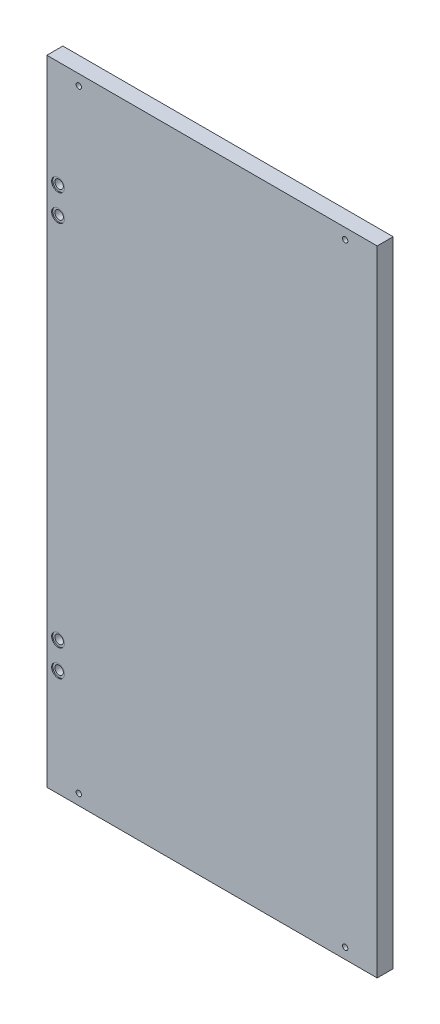
from build123d import *

# Parameters (mm, degrees)
SKETCH_1_W               = 310
SKETCH_1_H               = 595
EXTRUDE_1_DEPTH          = 15
SKETCH_2_R               = 4
CUT_EXTRUDE_2_DEPTH      = 336.791974294
SKETCH_2_5_R             = 2.5
CUT_EXTRUDE_3_DEPTH      = 336.791974294
MIRROR_3_COPY_1_SKETCH_R = 2.5
MIRROR_3_COPY_1_DEPTH    = 336.791974294
MIRROR_3_COPY_2_SKETCH_R = 2.5
MIRROR_3_COPY_2_DEPTH    = 336.791974294
SKETCH_3_R               = 6
CUT_EXTRUDE_4_DEPTH      = 1


with BuildPart() as part:
    # ｽｹｯﾁ1 → ﾎﾞｽ - 押し出し1 (new body)
    with BuildSketch(Plane.XY):
        Rectangle(SKETCH_1_W, SKETCH_1_H)
    extrude(amount=EXTRUDE_1_DEPTH)

    # ｽｹｯﾁ2 → ｶｯﾄ - 押し出し2 (cut, through all)
    with BuildSketch(Plane.XY.offset(15)):
        with Locations((-144.5, 197.5)):
            Circle(SKETCH_2_R)
        with Locations((-144.5, 172.5)):
            Circle(SKETCH_2_R)
    cut_extrude_2 = extrude(amount=-CUT_EXTRUDE_2_DEPTH, mode=Mode.SUBTRACT)

    # ｽｹｯﾁ2<5> → ｶｯﾄ - 押し出し3 (cut, through all)
    with BuildSketch(Plane.XY.offset(15)):
        with Locations((-125, 287.5)):
            Circle(SKETCH_2_5_R)
    cut_extrude_3 = extrude(amount=-CUT_EXTRUDE_3_DEPTH, mode=Mode.SUBTRACT)

    # ﾐﾗｰ1: ｶｯﾄ - 押し出し3 across plane
    add(cut_extrude_3.mirror(Plane.ZX), mode=Mode.SUBTRACT)

    # ﾐﾗｰ2: ｶｯﾄ - 押し出し2 across plane
    add(cut_extrude_2.mirror(Plane.ZX), mode=Mode.SUBTRACT)

    # ﾐﾗｰ3 copy 1 sketch → ﾐﾗｰ3 copy 1 (cut, through all)
    with BuildSketch(Plane(origin=(0, 0, 15), x_dir=(-1, 0, 0), z_dir=(0, 0, 1))):
        with Locations((-125, 287.5)):
            Circle(MIRROR_3_COPY_1_SKETCH_R)
    extrude(amount=-MIRROR_3_COPY_1_DEPTH, mode=Mode.SUBTRACT)

    # ﾐﾗｰ3 copy 2 sketch → ﾐﾗｰ3 copy 2 (cut, through all)
    with BuildSketch(Plane(origin=(0, 0, 15), x_dir=(-1, 0, 0), z_dir=(0, 0, 1))):
        with Locations((-125, -287.5)):
            Circle(MIRROR_3_COPY_2_SKETCH_R)
    extrude(amount=-MIRROR_3_COPY_2_DEPTH, mode=Mode.SUBTRACT)

    # ｽｹｯﾁ3 → ｶｯﾄ - 押し出し4 (cut)
    with BuildSketch(Plane.XY.offset(15)):
        with Locations((-144.5, 197.5)):
            Circle(SKETCH_3_R)
        with Locations((-144.5, 172.5)):
            Circle(SKETCH_3_R)
    cut_extrude_4 = extrude(amount=-CUT_EXTRUDE_4_DEPTH, mode=Mode.SUBTRACT)

    # ﾐﾗｰ4: ｶｯﾄ - 押し出し4 across plane
    add(cut_extrude_4.mirror(Plane.ZX), mode=Mode.SUBTRACT)


solid = part.part
